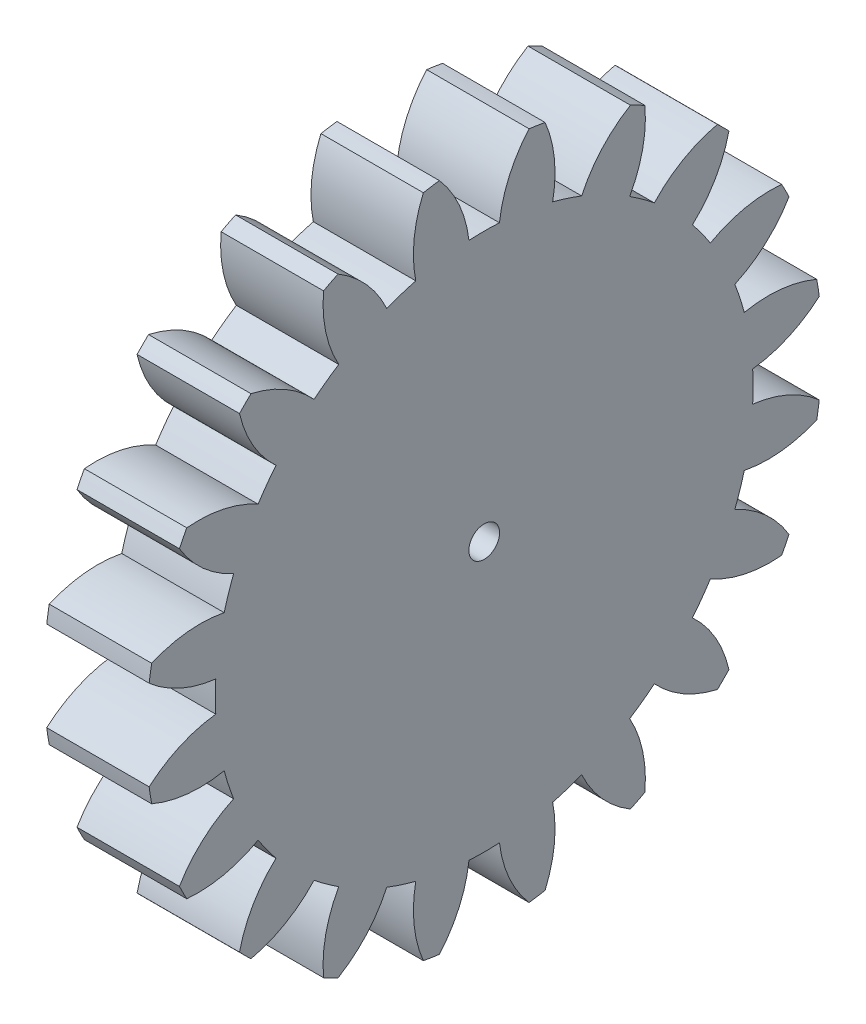
from build123d import *

# Parameters (mm, degrees)
BASPROSKE_W     = 5
BASPROSKE_H     = 16.5
TOOTHCUT_DEPTH  = 24.864199128
TEETHCUTS_COUNT = 20
TEETHCUTS_ANGLE = 342
BORSKE_R        = 0.75
BORE_DEPTH      = 50.0000508


with BuildPart() as part:
    # BasProSke → Base-Revolve (revolve)
    with BuildSketch(Plane(origin=(0, 0, 0), x_dir=(1, 0, 0), z_dir=(0, 1, 0)), mode=Mode.PRIVATE) as base_revolve_sk:
        with Locations((2.5, 8.25)):
            Rectangle(BASPROSKE_W, BASPROSKE_H)
    revolve(base_revolve_sk.sketch.rotate(Axis((-10, 0, 0), (1, 0, 0)), 180), axis=Axis((-10, 0, 0), (1, 0, 0)))

    # TooCutSke → ToothCut (cut, through all)
    with BuildSketch(Plane(origin=(0, 0, 0), x_dir=(0, 0, -1), z_dir=(1, 0, 0))):
        with BuildLine():
            ThreePointArc((0.74381438, 13.102904875), (0, 13.124), (-0.74381438, 13.102904875))
            ThreePointArc((-0.74381438, 13.102904875), (-1.226473103, 14.852072512), (-2.209965745, 16.376962373))
            ThreePointArc((-2.209965745, 16.376962373), (0, 16.5254), (2.209965745, 16.376962373))
            ThreePointArc((2.209965745, 16.376962373), (1.226473103, 14.852072512), (0.74381438, 13.102904875))
        make_face()
    toothcut = extrude(amount=TOOTHCUT_DEPTH, mode=Mode.SUBTRACT)

    # TeethCuts: ToothCut ×20 about axis
    teethcuts_axis = Axis((-10, 0, 0), (1, 0, 0))
    for i in range(1, TEETHCUTS_COUNT):
        add(toothcut.rotate(teethcuts_axis, i * TEETHCUTS_ANGLE / (TEETHCUTS_COUNT - 1)), mode=Mode.SUBTRACT)

    # BorSke → Bore (cut, symmetric)
    with BuildSketch(Plane(origin=(0, 0, 0), x_dir=(0, 0, -1), z_dir=(1, 0, 0))):
        with Locations(Location((0, 0, 0), (0, 0, 180))):
            Circle(BORSKE_R)
    extrude(amount=BORE_DEPTH, both=True, mode=Mode.SUBTRACT)


solid = part.part
